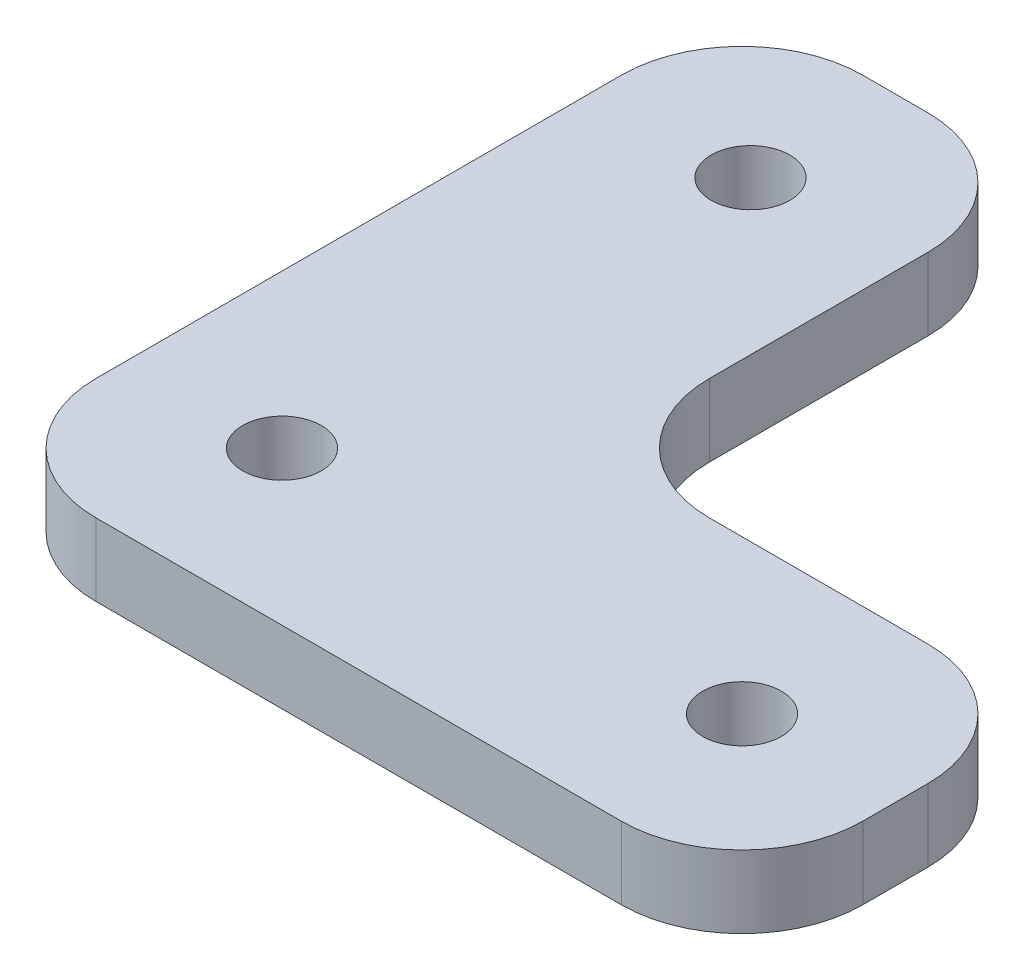
from build123d import *

# Parameters (mm, degrees)
SKETCH1_W           = 25.4
SKETCH1_H           = 63.5
SKETCH1_R           = 3.25755
SKETCH1_W_2         = 38.1
SKETCH1_H_2         = 25.4
BOSS_EXTRUDE1_DEPTH = 6
FILLET1_R           = 10


with BuildPart() as part:
    # Sketch1 → Boss-Extrude1 (new body)
    with BuildSketch(Plane(origin=(0, 0, 0), x_dir=(1, 0, 0), z_dir=(0, 1, 0))):
        with Locations((12.7, 31.75)):
            Rectangle(SKETCH1_W, SKETCH1_H)
        with Locations((12.7, 12.7)):
            Circle(SKETCH1_R, mode=Mode.SUBTRACT)
        with Locations((12.7, 51.5)):
            Circle(SKETCH1_R, mode=Mode.SUBTRACT)
        with Locations((44.45, 12.7)):
            Rectangle(SKETCH1_W_2, SKETCH1_H_2)
        with Locations((50.8, 12.7)):
            Circle(SKETCH1_R, mode=Mode.SUBTRACT)
    extrude(amount=BOSS_EXTRUDE1_DEPTH)

    # Fillet1
    fillet1_edges = [part.edges().sort_by_distance(p)[0] for p in [
        (0, 3, 0),
        (0, 3, -63.5),
        (25.4, 3, -63.5),
        (25.4, 3, -25.4),
        (63.5, 3, -25.4),
        (63.5, 3, 0),
    ]]
    fillet(fillet1_edges, radius=FILLET1_R)


solid = part.part
